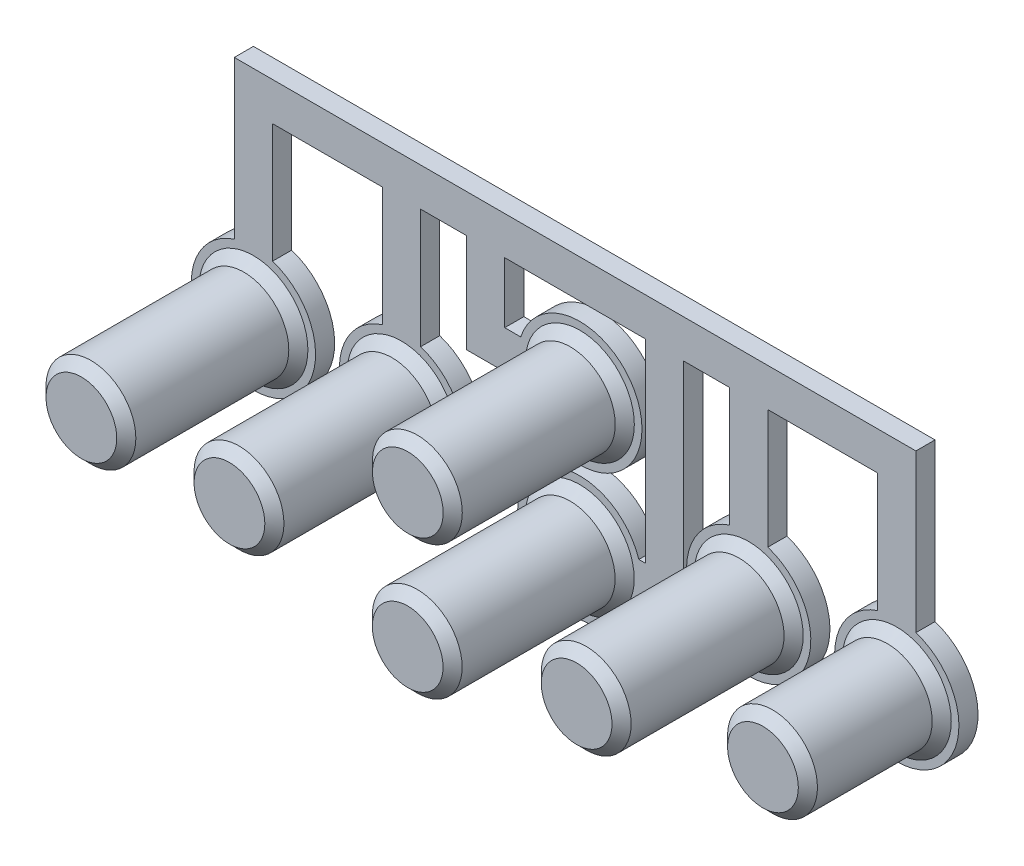
from build123d import *

# Parameters (mm, degrees)
SKIZZE1_R                         = 2.35
AUFSATZ_LINEAR_AUSTRAGEN1_DEPTH   = 10
AUFSATZ_LINEAR_AUSTRAGEN1_2_DEPTH = 10
AUFSATZ_LINEAR_AUSTRAGEN1_3_DEPTH = 10
AUFSATZ_LINEAR_AUSTRAGEN1_4_DEPTH = 10
AUFSATZ_LINEAR_AUSTRAGEN1_5_DEPTH = 10
SKIZZE1_3_R                       = 2.35
AUFSATZ_LINEAR_AUSTRAGEN4_DEPTH   = 8
SKIZZE2_R                         = 3.25
AUFSATZ_LINEAR_AUSTRAGEN2_DEPTH   = 1
AUFSATZ_LINEAR_AUSTRAGEN3_DEPTH   = 1
FASE1_SIZE                        = 0.5
FASE2_SIZE                        = 0.5
FASE3_SIZE                        = 0.5


with BuildPart() as part:
    # Skizze1 → Aufsatz-Linear austragen1 (new body)
    with BuildSketch(Plane.XY):
        with Locations((-17.068817434, 1.838554139)):
            Circle(SKIZZE1_R)
    extrude(amount=AUFSATZ_LINEAR_AUSTRAGEN1_DEPTH)



with BuildPart() as body_2:
    # Skizze1 → Aufsatz-Linear austragen1 2 (new body)
    with BuildSketch(Plane.XY):
        with Locations((-9.321817434, 1.838554139)):
            Circle(SKIZZE1_R)
    extrude(amount=AUFSATZ_LINEAR_AUSTRAGEN1_2_DEPTH)


with BuildPart() as body_3:
    # Skizze1 → Aufsatz-Linear austragen1 3 (new body)
    with BuildSketch(Plane.XY):
        Circle(SKIZZE1_R)
    extrude(amount=AUFSATZ_LINEAR_AUSTRAGEN1_3_DEPTH)


with BuildPart() as body_4:
    # Skizze1 → Aufsatz-Linear austragen1 4 (new body)
    with BuildSketch(Plane.XY):
        with Locations((0.007570249, 6.993531953)):
            Circle(SKIZZE1_R)
    extrude(amount=AUFSATZ_LINEAR_AUSTRAGEN1_4_DEPTH)


with BuildPart() as body_5:
    # Skizze1 → Aufsatz-Linear austragen1 5 (new body)
    with BuildSketch(Plane.XY):
        with Locations((8.839182566, 1.838554139)):
            Circle(SKIZZE1_R)
    extrude(amount=AUFSATZ_LINEAR_AUSTRAGEN1_5_DEPTH)


with BuildPart() as body_6:
    # Skizze1_3 → Aufsatz-Linear austragen4 (new body)
    with BuildSketch(Plane.XY):
        with Locations((16.586182566, 1.838554139)):
            Circle(SKIZZE1_3_R)
    extrude(amount=AUFSATZ_LINEAR_AUSTRAGEN4_DEPTH)


with BuildPart() as part_1:
    add(part.part)

    add(body_2.part)  # Aufsatz-Linear austragen2 merges body 2

    add(body_3.part)  # Aufsatz-Linear austragen2 merges body 3

    add(body_4.part)  # Aufsatz-Linear austragen2 merges body 4

    add(body_5.part)  # Aufsatz-Linear austragen2 merges body 5

    add(body_6.part)  # Aufsatz-Linear austragen2 merges body 6
    # Skizze2 → Aufsatz-Linear austragen2 (add)
    with BuildSketch(Plane.XY):
        with Locations((-17.068817434, 1.838554139)):
            Circle(SKIZZE2_R)
        with Locations((-9.321817434, 1.838554139)):
            Circle(SKIZZE2_R)
        Circle(SKIZZE2_R)
        with Locations((0.007570249, 6.993531953)):
            Circle(SKIZZE2_R)
        with Locations((8.839182566, 1.838554139)):
            Circle(SKIZZE2_R)
        with Locations((16.586182566, 1.838554139)):
            Circle(SKIZZE2_R)
    extrude(amount=AUFSATZ_LINEAR_AUSTRAGEN2_DEPTH)

    # Skizze3 → Aufsatz-Linear austragen3 (add)
    with BuildSketch(Plane.XY):
        Polygon((-18.068817434, 13.164615586), (-18.068817434, 4.930883358), (-16.068817434, 4.930883358), (-16.068817434, 11.164615586), (-10.321817434, 11.164615586), (-10.321817434, 4.930883358), (-8.321817434, 4.930883358), (-8.321817434, 11.164615586), (-5.921817434, 11.164615586), (-5.921817434, 5.993531953), (-3.08475897, 5.993531953), (-3.08475897, 7.993531953), (-3.921817434, 7.993531953), (-3.921817434, 11.164615586), (3.439182566, 11.164615586), (3.439182566, 1), (3.092329219, 1), (3.092329219, -1), (3.439182566, -1), (5.439182566, -1), (5.439182566, 1), (5.439182566, 11.164615586), (7.839182566, 11.164615586), (7.839182566, 4.930883358), (9.839182566, 4.930883358), (9.839182566, 11.164615586), (15.586182566, 11.164615586), (15.586182566, 4.930883358), (17.586182566, 4.930883358), (17.586182566, 13.164615586), align=None)
    extrude(amount=AUFSATZ_LINEAR_AUSTRAGEN3_DEPTH)

    # Fase1
    fase1_edges = [part_1.edges().sort_by_distance(p)[0] for p in [
        (-19.418817434, 1.838554139, 10),
        (-2.35, 0, 10),
        (-2.342429751, 6.993531953, 10),
        (6.489182566, 1.838554139, 10),
        (-11.671817434, 1.838554139, 10),
    ]]
    chamfer(fase1_edges, length=FASE1_SIZE)

    # Fase2
    fase2_edges = [part_1.edges().sort_by_distance(p)[0] for p in [
        (-19.418817434, 1.838554139, 1),
        (-2.35, 0, 1),
        (-2.342429751, 6.993531953, 1),
        (6.489182566, 1.838554139, 1),
        (14.236182566, 1.838554139, 1),
        (-11.671817434, 1.838554139, 1),
    ]]
    chamfer(fase2_edges, length=FASE2_SIZE)

    # Fase3
    fase3_edges = [part_1.edges().sort_by_distance(p)[0] for p in [
        (14.236182566, 1.838554139, 8),
    ]]
    chamfer(fase3_edges, length=FASE3_SIZE)


solid = part_1.part
